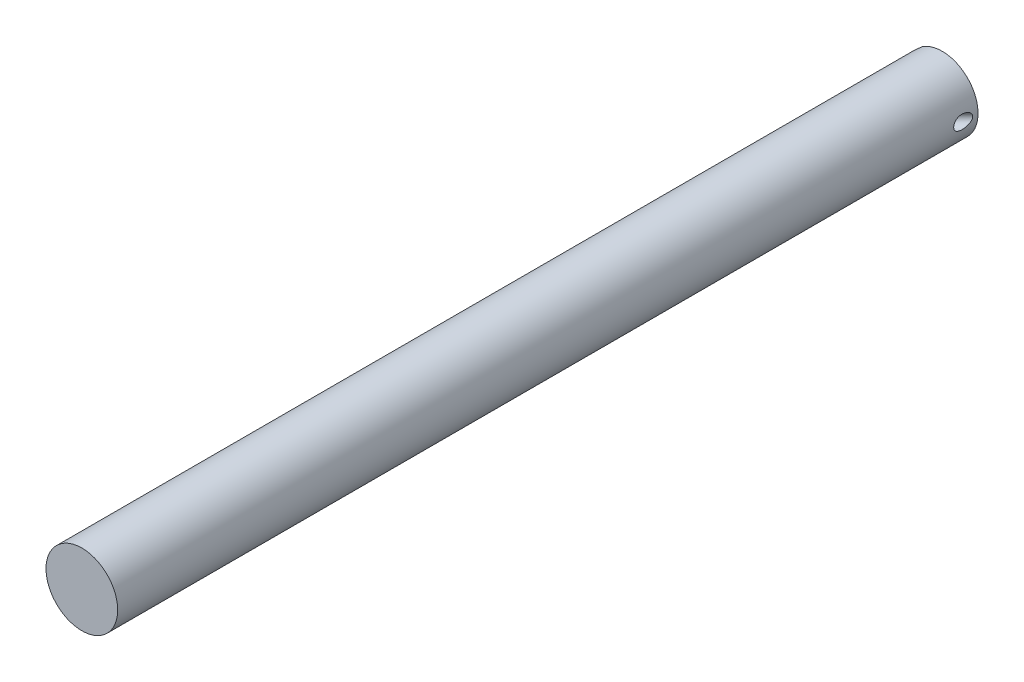
from build123d import *

# Parameters (mm, degrees)
SKETCH1_R                   = 12.7
EXTRUDE1_DEPTH              = 304.8
SKETCH4_R                   = 2.38125
EXTRUDE2_DEPTH              = 306.328708116
EXTRUDE2_DEPTH_BACK         = 306.328708116
SKETCH6_W                   = 20.167016722
SKETCH6_H                   = 37.330359398
EXTRUDE3_DEPTH              = 63.5
F_10_24_TAPPED_HOLE1_REACH  = 305.254
F_10_24_TAPPED_HOLE1_BORE_R = 1.89865
SKETCH10_R                  = 3.96875
EXTRUDE4_DEPTH              = 288.166292049


with BuildPart() as part:
    # Sketch1 → Extrude1 (new body)
    with BuildSketch(Plane.XY):
        with Locations(Location((0, 0, 0), (0, 0, 180))):
            Circle(SKETCH1_R)
    extrude(amount=EXTRUDE1_DEPTH)

    # Sketch4 → Extrude2 (cut, two sides)
    with BuildSketch(Plane(origin=(0, 0, 0), x_dir=(0.7071067811865462, 0, 0.7071067811865488), z_dir=(-0.7071067811865488, 0, 0.7071067811865462))) as extrude2_sk:
        with Locations((12.7, 0)):
            Circle(SKETCH4_R)
    extrude(amount=EXTRUDE2_DEPTH, mode=Mode.SUBTRACT)
    extrude(extrude2_sk.sketch, amount=-EXTRUDE2_DEPTH_BACK, mode=Mode.SUBTRACT)

    # Sketch6 → Extrude3 (cut)
    with BuildSketch(Plane(origin=(-3.592102448, 0, -3.592102448), x_dir=(-0.7071067811865512, 0, 0.7071067811865438), z_dir=(-0.7071067811865438, 0, -0.7071067811865512))):
        with Locations((5.167476491, 0)):
            Rectangle(SKETCH6_W, SKETCH6_H)
    extrude(amount=EXTRUDE3_DEPTH, mode=Mode.SUBTRACT)

    # #10-24 Tapped Hole1 bore (on position points) → #10-24 Tapped Hole1 (cut, up to next)
    with BuildSketch(Plane(origin=(-9.846920352, -0.244294465, 2.662715455), x_dir=(-0.707106781187, 0, 0.707106781187), z_dir=(-0.707106781187, 0, -0.707106781187)), mode=Mode.PRIVATE) as f_10_24_tapped_hole1_sk1:
        Circle(F_10_24_TAPPED_HOLE1_BORE_R)
    f_10_24_tapped_hole1_tool1 = extrude(f_10_24_tapped_hole1_sk1.sketch, amount=-F_10_24_TAPPED_HOLE1_REACH, mode=Mode.PRIVATE) & part.part
    add(f_10_24_tapped_hole1_tool1.solids().sort_by_distance((-9.84692, -0.244294, 2.662715))[0], mode=Mode.SUBTRACT)

    # Sketch10 → Extrude4 (cut, through all)
    with BuildSketch(Plane(origin=(-19.756563466, 0, 19.756563466), x_dir=(0.7071067811865462, 0, 0.7071067811865488), z_dir=(-0.7071067811865488, 0, 0.7071067811865462))):
        with Locations((12.7, 0)):
            Circle(SKETCH10_R)
    extrude(amount=EXTRUDE4_DEPTH, mode=Mode.SUBTRACT)


solid = part.part
